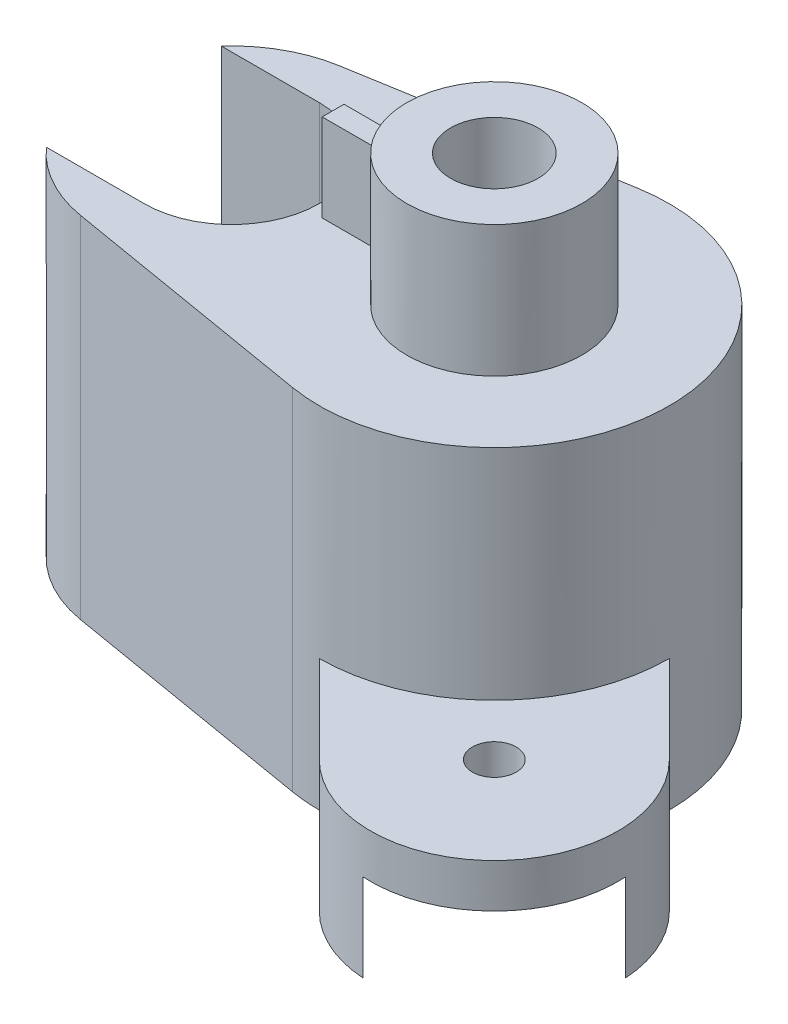
from build123d import *

# Parameters (mm, degrees)
BOSS_EXTRUDE1_DEPTH        = 80
SKETCH2_R                  = 30
CUT_EXTRUDE1_DEPTH         = 30
SKETCH3_R                  = 20
BOSS_EXTRUDE2_DEPTH        = 30
F_20_0MM_DOWEL_HOLE1_D     = 20
F_20_0MM_DOWEL_HOLE1_DEPTH = 30
F_20_0MM_DOWEL_HOLE1_TIP   = 6.00860619
SKETCH6_R                  = 10
CUT_EXTRUDE2_DEPTH         = 109
SKETCH7_R                  = 10
CUT_EXTRUDE3_DEPTH         = 60
BOSS_EXTRUDE3_DEPTH        = 30
SKETCH11_R                 = 5
CUT_EXTRUDE4_DEPTH         = 30
SKETCH13_R                 = 5
CUT_EXTRUDE5_DEPTH         = 20
SKETCH14_W                 = 17
SKETCH14_H                 = 5
BOSS_EXTRUDE4_DEPTH        = 20


with BuildPart() as part:
    # Sketch1 → Boss-Extrude1 (new body)
    with BuildSketch(Plane(origin=(0, 0, 0), x_dir=(1, 0, 0), z_dir=(0, 1, 0))):
        with BuildLine():
            Line((-6.666666667, 39.440531887), (-65, 29.580398915))
            ThreePointArc((-65, 29.580398915), (-74.494747679, 26.265991124), (-82.360679775, 20))
            ThreePointArc((-82.360679775, 20), (-90, 0), (-82.360679775, -20))
            ThreePointArc((-82.360679775, -20), (-74.494747679, -26.265991124), (-65, -29.580398915))
            Line((-65, -29.580398915), (-6.666666667, -39.440531887))
            ThreePointArc((-6.666666667, -39.440531887), (-3.345050411, -39.859887578), (0, -40))
            ThreePointArc((0, -40), (40, 0), (0, 40))
            ThreePointArc((0, 40), (-3.345050411, 39.859887578), (-6.666666667, 39.440531887))
        make_face()
    extrude(amount=BOSS_EXTRUDE1_DEPTH)

    # Sketch2 → Cut-Extrude1 (cut)
    with BuildSketch(Plane.XZ):
        Circle(SKETCH2_R)
    extrude(amount=-CUT_EXTRUDE1_DEPTH, mode=Mode.SUBTRACT)

    # Sketch3 → Boss-Extrude2 (add)
    with BuildSketch(Plane(origin=(0, 80, 0), x_dir=(1, 0, 0), z_dir=(0, 1, 0))):
        Circle(SKETCH3_R)
    extrude(amount=BOSS_EXTRUDE2_DEPTH)

    # Ø20.0mm Dowel Hole1
    with Locations(Plane.ZX.offset(110)):
        with Locations((0, 0)):
            Hole(F_20_0MM_DOWEL_HOLE1_D / 2, depth=F_20_0MM_DOWEL_HOLE1_DEPTH)
            with Locations((0, 0, -(F_20_0MM_DOWEL_HOLE1_DEPTH + F_20_0MM_DOWEL_HOLE1_TIP / 2))):  # 118° drill point
                Cone(0, F_20_0MM_DOWEL_HOLE1_D / 2, F_20_0MM_DOWEL_HOLE1_TIP, mode=Mode.SUBTRACT)

    # Sketch6 → Cut-Extrude2 (cut)
    with BuildSketch(Plane(origin=(0, 80, 0), x_dir=(1, 0, 0), z_dir=(0, 1, 0))):
        with Locations((-60, 0)):
            Circle(SKETCH6_R)
    extrude(amount=-CUT_EXTRUDE2_DEPTH, mode=Mode.SUBTRACT)

    # Sketch7 → Cut-Extrude3 (cut)
    with BuildSketch(Plane(origin=(0, 80, 0), x_dir=(1, 0, 0), z_dir=(0, 1, 0))):
        with BuildLine():
            ThreePointArc((-60, -20), (-40, 0), (-60, 20))
            Line((-60, 20), (-82.360679775, 20))
            ThreePointArc((-82.360679775, 20), (-90, 0), (-82.360679775, -20))
            Line((-82.360679775, -20), (-60, -20))
        make_face()
        with Locations((-60, 0)):
            Circle(SKETCH7_R, mode=Mode.SUBTRACT)
    extrude(amount=-CUT_EXTRUDE3_DEPTH, mode=Mode.SUBTRACT)

    # Sketch10 → Boss-Extrude3 (add)
    with BuildSketch(Plane.XZ):
        with BuildLine():
            Line((20, 60), (0, 40))
            ThreePointArc((0, 40), (28.284271247, 28.284271247), (40, 0))
            Line((40, 0), (60, 20))
            ThreePointArc((60, 20), (60, 60), (20, 60))
        make_face()
    extrude(amount=-BOSS_EXTRUDE3_DEPTH)

    # Sketch11 → Cut-Extrude4 (cut)
    with BuildSketch(Plane(origin=(0, 0, 0), x_dir=(-1, 0, 0), z_dir=(0, -1, 0))):
        with Locations((-40, -40)):
            Circle(SKETCH11_R)
    extrude(amount=-CUT_EXTRUDE4_DEPTH, mode=Mode.SUBTRACT)

    # Sketch13 → Cut-Extrude5 (cut)
    with BuildSketch(Plane(origin=(0, 0, 0), x_dir=(-1, 0, 0), z_dir=(0, -1, 0))):
        with BuildLine():
            ThreePointArc((-68.228756555, -38.228756555), (-60, -60), (-38.228756555, -68.228756555))
            Line((-38.228756555, -68.228756555), (0, -30))
            ThreePointArc((0, -30), (-21.213203436, -21.213203436), (-30, 0))
            Line((-30, 0), (-68.228756555, -38.228756555))
        make_face()
        with Locations((-40, -40)):
            Circle(SKETCH13_R, mode=Mode.SUBTRACT)
    extrude(amount=-CUT_EXTRUDE5_DEPTH, mode=Mode.SUBTRACT)

    # Sketch14 → Boss-Extrude4 (add)
    with BuildSketch(Plane(origin=(0, 80, 0), x_dir=(1, 0, 0), z_dir=(0, 1, 0))):
        with Locations((-28.343134833, 0)):
            Rectangle(SKETCH14_W, SKETCH14_H)
    extrude(amount=BOSS_EXTRUDE4_DEPTH)


solid = part.part
